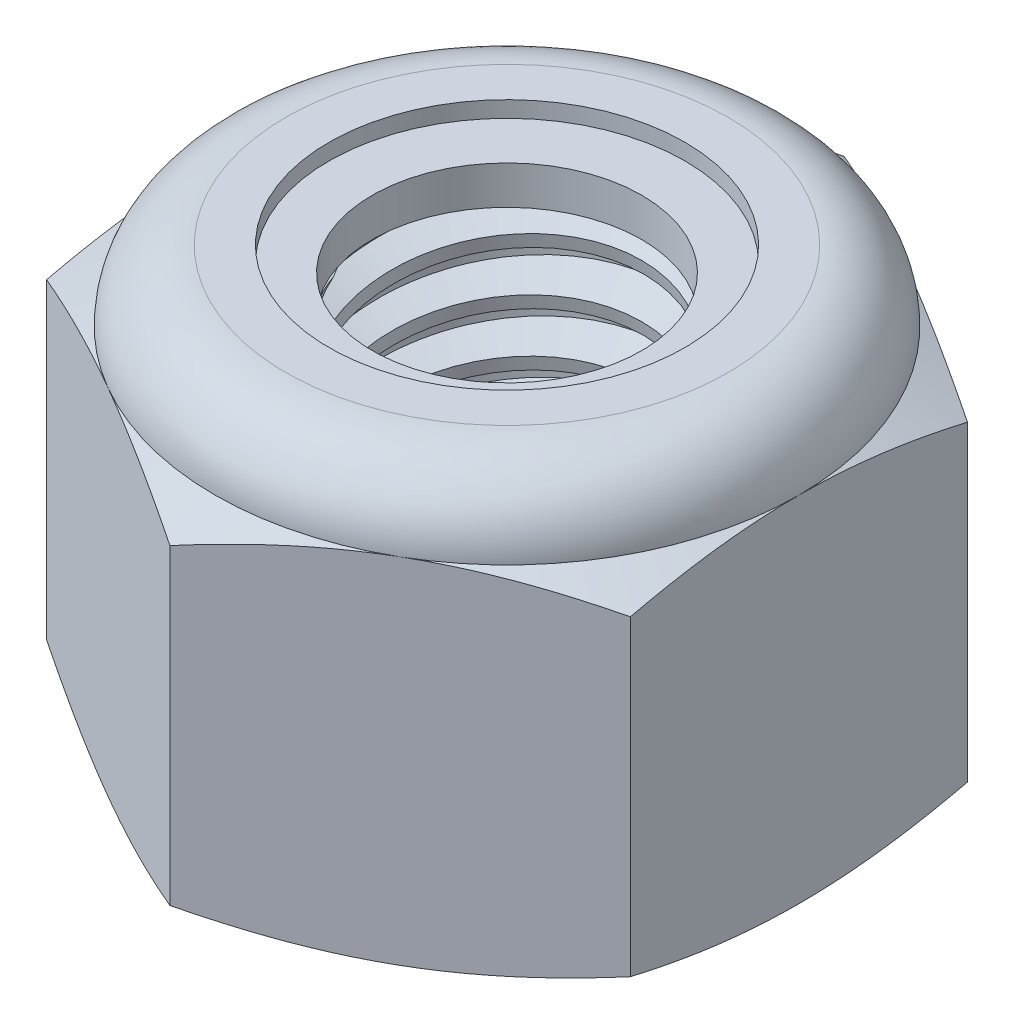
from build123d import *

# Parameters (mm, degrees)
EXTRUDE1_DEPTH      = 4
SKETCH2_W           = 1.5
SKETCH2_H           = 4
LPATTERN1_COUNT     = 8
LPATTERN1_PITCH     = 0.5
LPATTERN1_COL_COUNT = 2
LPATTERN1_COL_PITCH = 0.5


with BuildPart() as part:
    # Sketch1 → Extrude1 (new body)
    with BuildSketch(Plane(origin=(0, 0, 0), x_dir=(1, 0, 0), z_dir=(0, 1, 0))):
        Polygon((0, 3.175426481), (-2.75, 1.58771324), (-2.75, -1.58771324), (0, -3.175426481), (2.75, -1.58771324), (2.75, 1.58771324), align=None)
    extrude(amount=EXTRUDE1_DEPTH)

    # Sketch4 → Cut-Revolve2 (revolve, cut)
    with BuildSketch(Plane(origin=(0, 0, 0), x_dir=(0, 0, -1), z_dir=(1, 0, 0))):
        Polygon((0, 4), (1.5, 4), (1.269011592, 3.892288336), (1.269011592, 0.107711664), (1.5, 0), (0, 0), align=None)
    revolve(axis=Axis((0, 4, 0), (0, 1, 0)), mode=Mode.SUBTRACT)


with BuildPart() as body_2:
    # Sketch2 → Revolve1 (revolve)
    with BuildSketch(Plane(origin=(0, 0, 0), x_dir=(0, 0, -1), z_dir=(1, 0, 0))):
        with Locations((0.75, 2)):
            Rectangle(SKETCH2_W, SKETCH2_H)
    revolve(axis=Axis((0, -1.5, 0), (0, 1, 0)))

    # Sketch3 → Cut-Revolve1 (revolve, cut)
    with BuildSketch(Plane(origin=(0, 0, 0), x_dir=(0, 0, -1), z_dir=(1, 0, 0))):
        Polygon((1.510274937, 3.93835038), (1.582199494, 3.506803038), (1.289561466, 3.616435308), (1.269011592, 3.739734548), align=None)
    cut_revolve1 = revolve(axis=Axis((0, 4, 0.089188249), (0, -0.986393924, -0.164398987)), mode=Mode.SUBTRACT)

    # LPattern1: Cut-Revolve1 ×8
    with Locations(*[(0, -i * LPATTERN1_PITCH, 0) for i in range(1, LPATTERN1_COUNT)]):
        add(cut_revolve1, mode=Mode.SUBTRACT)

    # LPattern1 col: Cut-Revolve1 ×2
    with Locations(*[(0, i * LPATTERN1_COL_PITCH, 0) for i in range(1, LPATTERN1_COL_COUNT)]):
        add(cut_revolve1, mode=Mode.SUBTRACT)


with BuildPart() as part_1:
    add(part.part)

    # Combine1: cut body 2
    add(body_2.part, mode=Mode.SUBTRACT)

    # Sketch5 → Cut-Revolve3 (revolve, cut)
    with BuildSketch(Plane(origin=(0, 0, 0), x_dir=(0, 0, -1), z_dir=(1, 0, 0))):
        with BuildLine():
            Line((0, 0), (2.75, 0))
            Line((2.75, 0), (3.175426481, 0.198379626))
            Line((3.175426481, 0.198379626), (3.175426481, 3.134953707))
            Line((3.175426481, 3.134953707), (2.75, 3.333333333))
            ThreePointArc((2.75, 3.333333333), (2.554737854, 3.804737854), (2.083333333, 4))
            Line((2.083333333, 4), (2.083333333, 5.27))
            Line((2.083333333, 5.27), (4.445426481, 5.27))
            Line((4.445426481, 5.27), (4.445426481, -1.27))
            Line((4.445426481, -1.27), (0, -1.27))
            Line((0, -1.27), (0, 0))
        make_face()
    revolve(axis=Axis((0, 0, 0), (0, 1, 0)), mode=Mode.SUBTRACT)

    # Sketch6 → Cut-Revolve4 (revolve, cut)
    with BuildSketch(Plane(origin=(0, 0, 0), x_dir=(0, 0, -1), z_dir=(1, 0, 0))):
        with BuildLine():
            Line((0, 3.333333333), (2.5976, 3.333333333))
            ThreePointArc((2.5976, 3.333333333), (2.446974781, 3.696974781), (2.083333333, 3.8476))
            Line((2.083333333, 3.8476), (1.676172463, 3.8476))
            Line((1.676172463, 3.8476), (1.676172463, 5.27))
            Line((1.676172463, 5.27), (0, 5.27))
            Line((0, 5.27), (0, 3.333333333))
        make_face()
    revolve(axis=Axis((0, 5.27, 0), (0, 1, 0)), mode=Mode.SUBTRACT)


with BuildPart() as body_2_2:
    # Sketch7 → Revolve2 (revolve)
    with BuildSketch(Plane(origin=(0, 0, 0), x_dir=(0, 0, -1), z_dir=(1, 0, 0))):
        with BuildLine():
            Line((1.269011592, 3.409533333), (2.514721748, 3.409533333))
            ThreePointArc((2.514721748, 3.409533333), (2.36486639, 3.668954462), (2.083333333, 3.7714))
            Line((2.083333333, 3.7714), (1.269011592, 3.7714))
            Line((1.269011592, 3.7714), (1.269011592, 3.409533333))
        make_face()
    revolve(axis=Axis((0, 3.409533333, 0), (0, 1, 0)))


solid = Compound([part_1.part, body_2_2.part])
